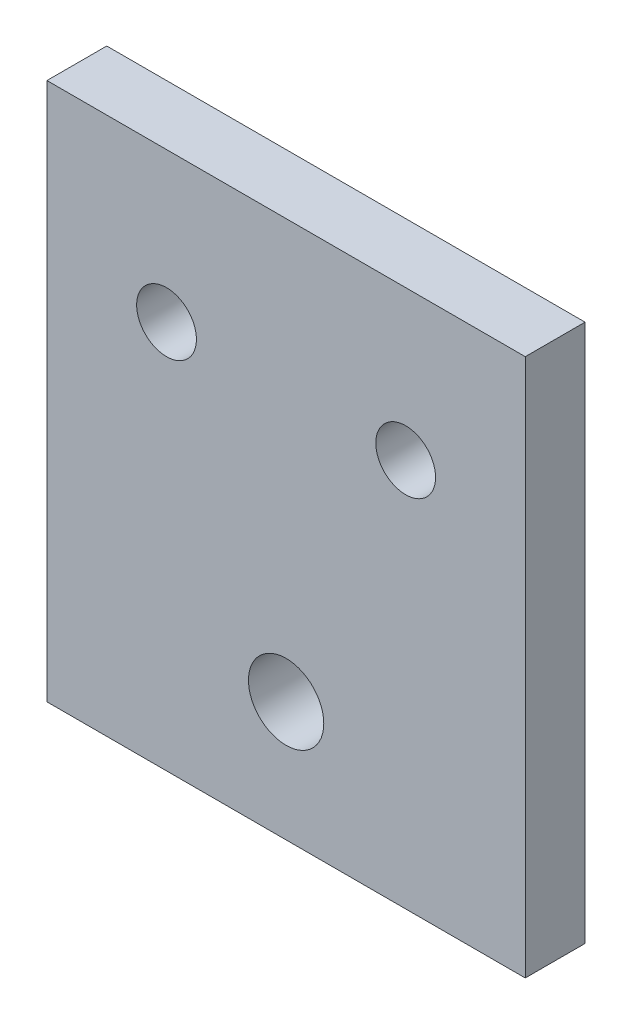
from build123d import *

# Parameters (mm, degrees)
SKETCH1_W           = 50.8
SKETCH1_H           = 57.15
BOSS_EXTRUDE1_DEPTH = 6.35
SKETCH4_R           = 4
SKETCH4_R_2         = 3.175
CUT_EXTRUDE1_DEPTH  = 6.35


with BuildPart() as part:
    # Sketch1 → Boss-Extrude1 (new body)
    with BuildSketch(Plane.XY):
        Rectangle(SKETCH1_W, SKETCH1_H)
    extrude(amount=BOSS_EXTRUDE1_DEPTH)

    # Sketch4 → Cut-Extrude1 (cut)
    with BuildSketch(Plane.XY.offset(6.35)):
        with Locations((0, -15.875)):
            Circle(SKETCH4_R)
        with Locations((-12.7, 12.7)):
            Circle(SKETCH4_R_2)
        with Locations((12.7, 12.7)):
            Circle(SKETCH4_R_2)
    extrude(amount=-CUT_EXTRUDE1_DEPTH, mode=Mode.SUBTRACT)


solid = part.part
